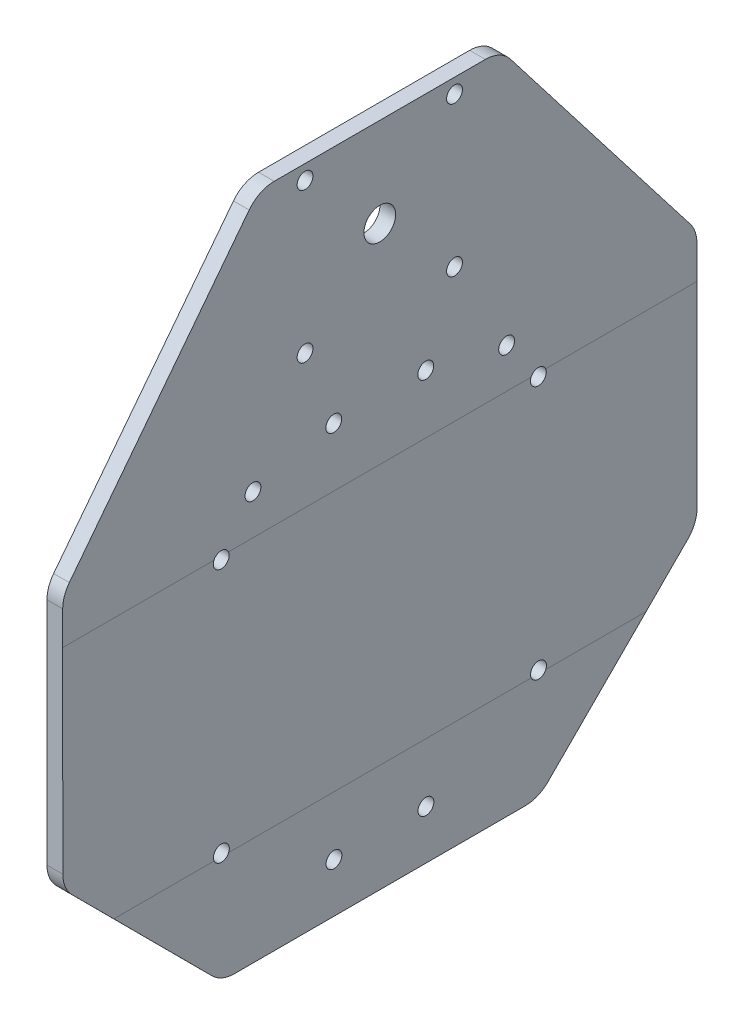
from build123d import *

# Parameters (mm, degrees)
SALIENTE_EXTRUIR1_DEPTH = 200
CROQUIS2_R              = 2.5
CORTAR_EXTRUIR1_DEPTH   = 100
CROQUIS3_W              = 4.95
CROQUIS3_H              = 200
SALIENTE_EXTRUIR2_DEPTH = 60
CROQUIS4_R              = 2.5
CROQUIS4_R_2            = 5
CORTAR_EXTRUIR2_DEPTH   = 60
REDONDEO1_R             = 10


with BuildPart() as part:
    # Croquis1 → Saliente-Extruir1 (new body)
    with BuildSketch(Plane.XY):
        Polygon((-38.444023, 46.698845), (-38.444023, -35.401155), (-38.444023, -69.401155), (-33.444023, -69.401155), (-33.444023, -35.401155), (-33.494023, 46.698845), (-33.494023, 80.698845), (-38.444023, 80.698845), align=None)
    extrude(amount=SALIENTE_EXTRUIR1_DEPTH)

    # Croquis2 → Cortar-Extruir1 (cut)
    with BuildSketch(Plane.ZY.offset(38.444023)):
        with Locations((85.5, 65.198845)):
            Circle(CROQUIS2_R)
        with Locations((114.5, 65.198845)):
            Circle(CROQUIS2_R)
        with Locations((50, 45.698845)):
            Circle(CROQUIS2_R)
        with Locations((150, 45.698845)):
            Circle(CROQUIS2_R)
        with Locations((150, -34.401155)):
            Circle(CROQUIS2_R)
        with Locations((114.5, -53.901155)):
            Circle(CROQUIS2_R)
        with Locations((85.5, -53.901155)):
            Circle(CROQUIS2_R)
        with Locations((50, -34.401155)):
            Circle(CROQUIS2_R)
    extrude(amount=-CORTAR_EXTRUIR1_DEPTH, mode=Mode.SUBTRACT)

    # Croquis3 → Saliente-Extruir2 (add)
    with BuildSketch(Plane(origin=(0, 80.698845, 0), x_dir=(1, 0, 0), z_dir=(0, 1, 0))):
        with Locations((-35.969023, -100)):
            Rectangle(CROQUIS3_W, CROQUIS3_H)
    extrude(amount=SALIENTE_EXTRUIR2_DEPTH)

    # Croquis4 → Cortar-Extruir2 (cut)
    with BuildSketch(Plane.ZY.offset(38.444023)):
        with Locations((76.43, 136.068845)):
            Circle(CROQUIS4_R)
        with Locations((123.57, 136.068845)):
            Circle(CROQUIS4_R)
        with Locations((76.43, 88.928845)):
            Circle(CROQUIS4_R)
        with Locations((123.57, 88.928845)):
            Circle(CROQUIS4_R)
        with Locations((100, 112.498845)):
            Circle(CROQUIS4_R_2)
        with Locations((60, 59.298845)):
            Circle(CROQUIS4_R)
        with Locations((140, 59.298845)):
            Circle(CROQUIS4_R)
        Polygon((61.8, 140.698845), (0, 60.698845), (0, 140.698845), align=None)
        Polygon((0, -19.301155), (50, -69.401155), (0, -69.401155), align=None)
        Polygon((200, -19.301155), (150, -69.401155), (200, -69.401155), align=None)
        Polygon((138.2, 140.698845), (200, 60.698845), (200, 140.698845), align=None)
    extrude(amount=-CORTAR_EXTRUIR2_DEPTH, mode=Mode.SUBTRACT)

    # Redondeo1
    redondeo1_edges = [part.edges().sort_by_distance(p)[0] for p in [
        (-35.969023, 60.698845, 0),
        (-35.944023, -69.401155, 50),
        (-35.944023, -69.401155, 150),
        (-35.969023, 60.698845, 200),
        (-35.969023, 140.698845, 138.2),
        (-35.969023, 140.698845, 61.8),
        (-35.948925, -19.301155, 0),
        (-35.948925, -19.301155, 200),
    ]]
    fillet(redondeo1_edges, radius=REDONDEO1_R)


solid = part.part
